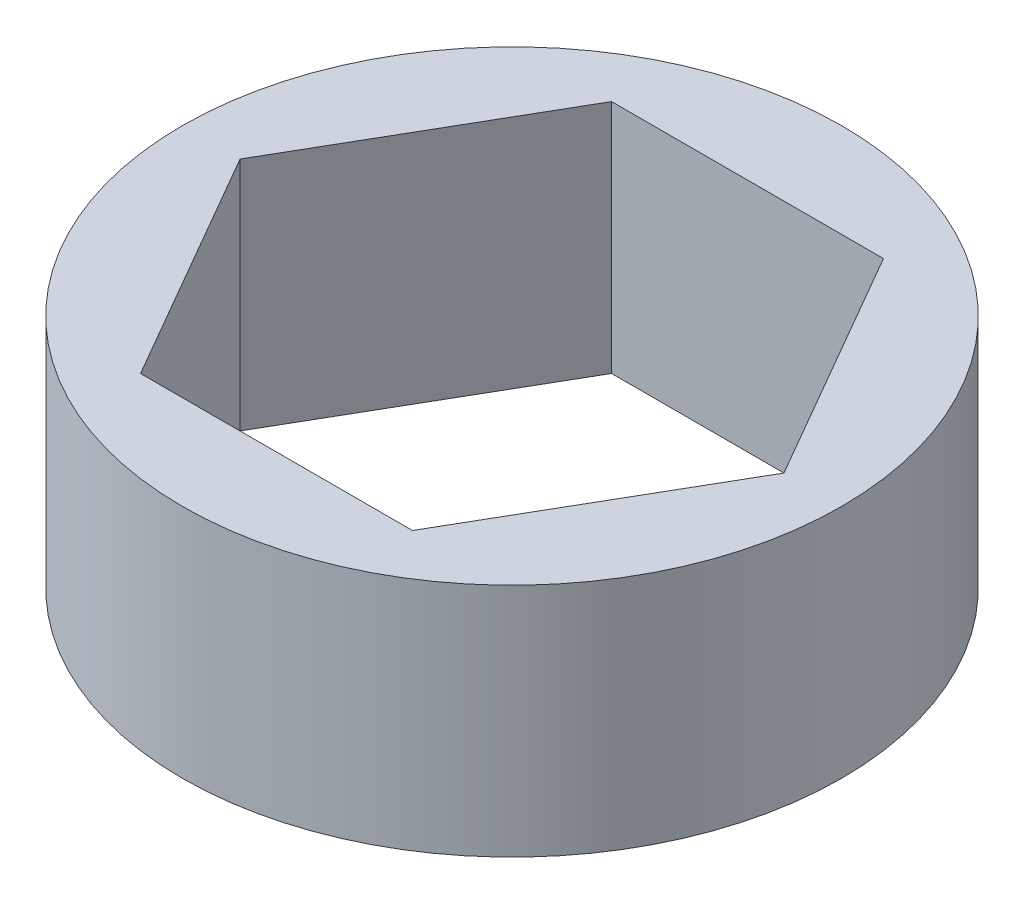
from build123d import *

# Parameters (mm, degrees)
SKETCH1_R           = 8.89
BOSS_EXTRUDE1_DEPTH = 6.35


with BuildPart() as part:
    # Sketch1 → Boss-Extrude1 (new body)
    with BuildSketch(Plane(origin=(0, 0, 0), x_dir=(1, 0, 0), z_dir=(0, 1, 0))):
        Circle(SKETCH1_R)
        Polygon((7.332348419, 0), (3.666174209, 6.35), (-3.666174209, 6.35), (-7.332348419, 0), (-3.666174209, -6.35), (3.666174209, -6.35), align=None, mode=Mode.SUBTRACT)
    extrude(amount=BOSS_EXTRUDE1_DEPTH)


solid = part.part
